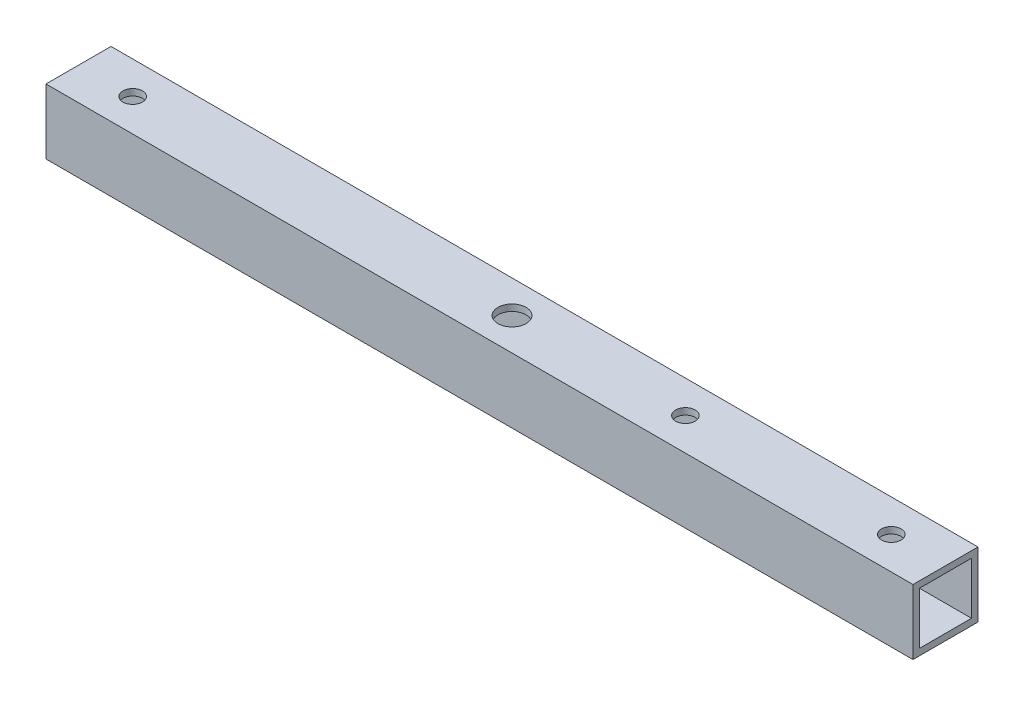
from build123d import *

# Parameters (mm, degrees)
SKETCH1_W           = 15
SKETCH1_H           = 15
SKETCH1_W_2         = 12
SKETCH1_H_2         = 12
BOSS_EXTRUDE1_DEPTH = 200
SKETCH2_R           = 3.25
SKETCH2_R_2         = 2.25
CUT_EXTRUDE1_DEPTH  = 16
SKETCH3_R           = 2.25
CUT_EXTRUDE2_DEPTH  = 16


with BuildPart() as part:
    # Sketch1 → Boss-Extrude1 (new body)
    with BuildSketch(Plane(origin=(0, 0, 0), x_dir=(0, 0, -1), z_dir=(1, 0, 0))):
        Rectangle(SKETCH1_W, SKETCH1_H)
        Rectangle(SKETCH1_W_2, SKETCH1_H_2, mode=Mode.SUBTRACT)
    extrude(amount=BOSS_EXTRUDE1_DEPTH)

    # Sketch2 → Cut-Extrude1 (cut, through all)
    with BuildSketch(Plane(origin=(0, 7.5, 0), x_dir=(1, 0, 0), z_dir=(0, 1, 0))):
        with Locations((100, 0)):
            Circle(SKETCH2_R)
        with Locations((140, 0)):
            Circle(SKETCH2_R_2)
    extrude(amount=-CUT_EXTRUDE1_DEPTH, mode=Mode.SUBTRACT)

    # Sketch3 → Cut-Extrude2 (cut, through all)
    with BuildSketch(Plane(origin=(0, 7.5, 0), x_dir=(1, 0, 0), z_dir=(0, 1, 0))):
        with Locations((12.5, 0)):
            Circle(SKETCH3_R)
        with Locations((187.5, 0)):
            Circle(SKETCH3_R)
    extrude(amount=-CUT_EXTRUDE2_DEPTH, mode=Mode.SUBTRACT)


solid = part.part
